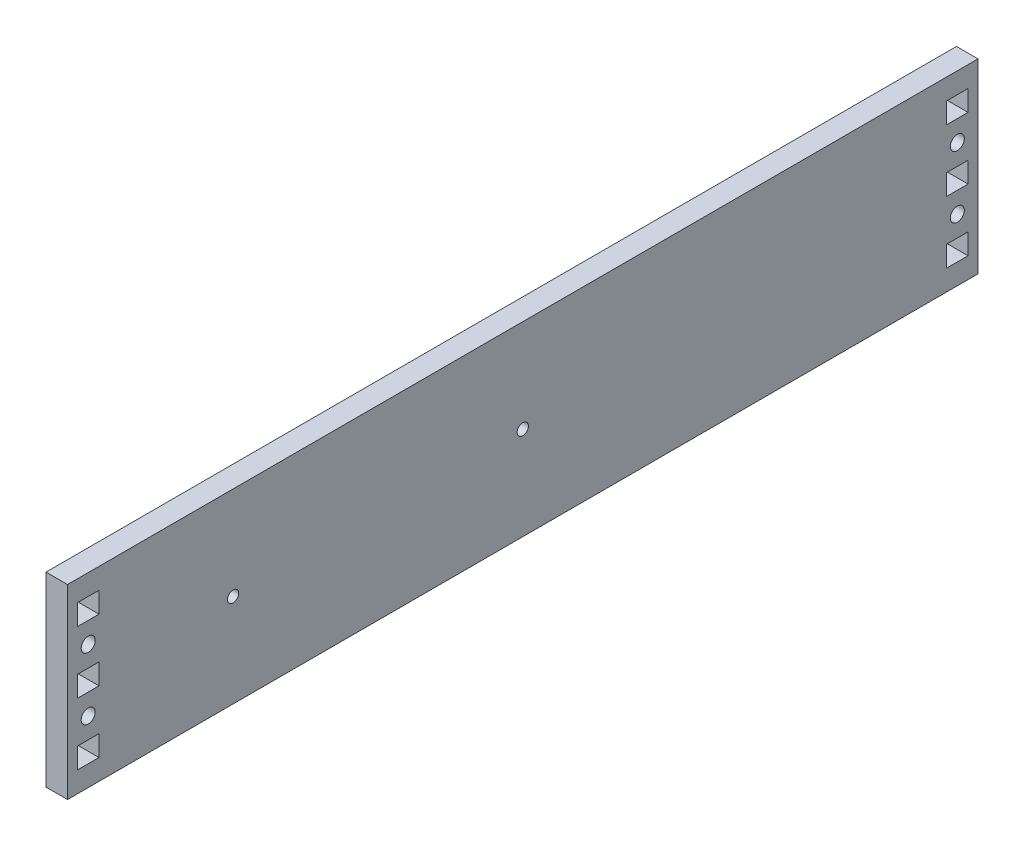
from build123d import *

# Parameters (mm, degrees)
SKETCH1_W                                         = 279.4
SKETCH1_H                                         = 57.15
SKETCH1_R                                         = 2.15265
SKETCH1_W_2                                       = 6.604
SKETCH1_H_2                                       = 6.35
BOSS_EXTRUDE1_DEPTH                               = 6.604
CSK_FOR_8_FLAT_HEAD_SOCKET_CAP_SCREW1_D           = 4.3053
CSK_FOR_8_FLAT_HEAD_SOCKET_CAP_SCREW1_CSINK_D     = 9.1186
CSK_FOR_8_FLAT_HEAD_SOCKET_CAP_SCREW1_CSINK_ANGLE = 82
F_8_32_TAPPED_HOLE1_D                             = 3.4544
F_8_32_TAPPED_HOLE1_DEPTH                         = 10.7188
F_8_32_TAPPED_HOLE1_TIP                           = 1.037806461


with BuildPart() as part:
    # Sketch1 → Boss-Extrude1 (new body)
    with BuildSketch(Plane(origin=(0, 0, 0), x_dir=(0, 0, -1), z_dir=(1, 0, 0))):
        Rectangle(SKETCH1_W, SKETCH1_H)
        with Locations((-133.35, 9.525)):
            Circle(SKETCH1_R, mode=Mode.SUBTRACT)
        with Locations((-133.35, -9.525)):
            Circle(SKETCH1_R, mode=Mode.SUBTRACT)
        with Locations((133.35, 9.525)):
            Circle(SKETCH1_R, mode=Mode.SUBTRACT)
        with Locations((133.35, -9.525)):
            Circle(SKETCH1_R, mode=Mode.SUBTRACT)
        with Locations((-133.35, 0)):
            Rectangle(SKETCH1_W_2, SKETCH1_H_2, mode=Mode.SUBTRACT)
        with Locations((-133.35, 19.05)):
            Rectangle(SKETCH1_W_2, SKETCH1_H_2, mode=Mode.SUBTRACT)
        with Locations((-133.35, -19.05)):
            Rectangle(SKETCH1_W_2, SKETCH1_H_2, mode=Mode.SUBTRACT)
        with Locations((133.35, 0)):
            Rectangle(SKETCH1_W_2, SKETCH1_H_2, mode=Mode.SUBTRACT)
        with Locations((133.35, 19.05)):
            Rectangle(SKETCH1_W_2, SKETCH1_H_2, mode=Mode.SUBTRACT)
        with Locations((133.35, -19.05)):
            Rectangle(SKETCH1_W_2, SKETCH1_H_2, mode=Mode.SUBTRACT)
    extrude(amount=BOSS_EXTRUDE1_DEPTH)

    # CSK for #8 Flat Head Socket Cap Screw1 (through all)
    with Locations(Plane.ZY):
        with Locations((-133.35, 9.525), (-133.35, -9.525), (133.35, 9.525), (133.35, -9.525)):
            CounterSinkHole(CSK_FOR_8_FLAT_HEAD_SOCKET_CAP_SCREW1_D / 2, CSK_FOR_8_FLAT_HEAD_SOCKET_CAP_SCREW1_CSINK_D / 2, counter_sink_angle=CSK_FOR_8_FLAT_HEAD_SOCKET_CAP_SCREW1_CSINK_ANGLE)

    # #8-32 Tapped Hole1
    with Locations(Plane.ZY):
        with Locations((88.9, 0), (0, 0)):
            Hole(F_8_32_TAPPED_HOLE1_D / 2, depth=F_8_32_TAPPED_HOLE1_DEPTH)
            with Locations((0, 0, -(F_8_32_TAPPED_HOLE1_DEPTH + F_8_32_TAPPED_HOLE1_TIP / 2))):  # 118° drill point
                Cone(0, F_8_32_TAPPED_HOLE1_D / 2, F_8_32_TAPPED_HOLE1_TIP, mode=Mode.SUBTRACT)


solid = part.part
